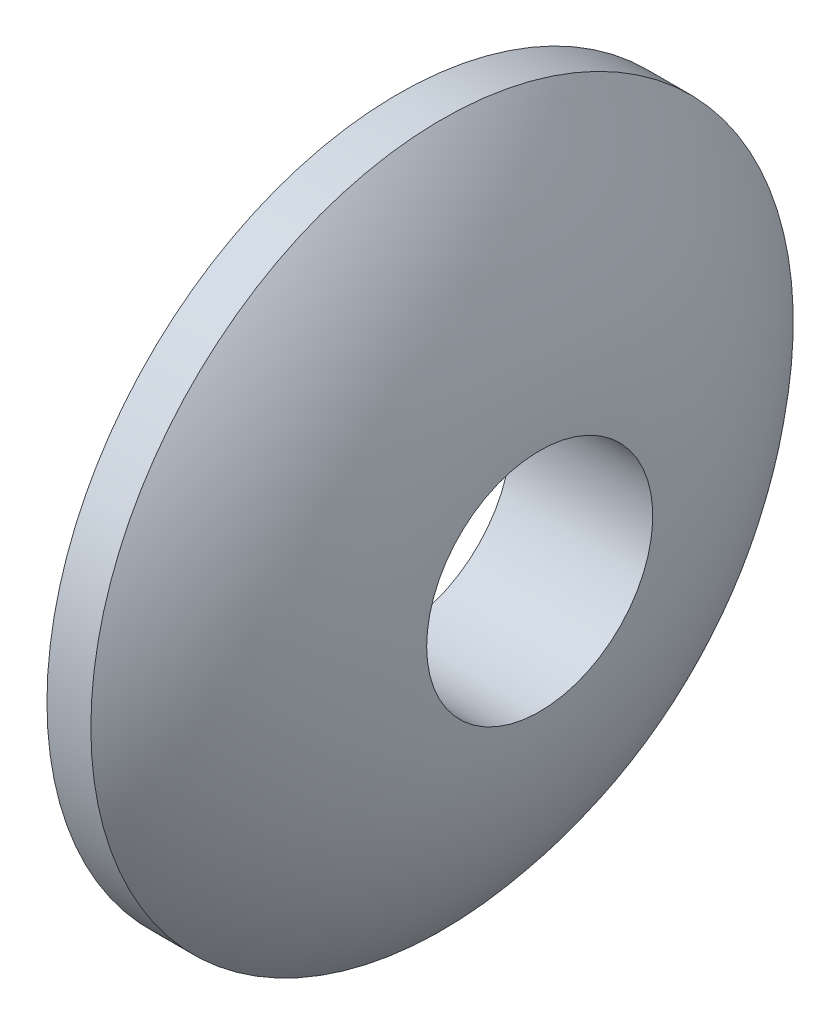
from build123d import *

# Parameters (mm, degrees)
SKETCH2_R          = 2.575
CUT_EXTRUDE1_DEPTH = 4.238860099


with BuildPart() as part:
    # Sketch1 → Revolve1 (revolve)
    with BuildSketch(Plane.XY):
        with BuildLine():
            Line((0, 0), (0, 8))
            Line((0, 8), (1, 8))
            ThreePointArc((1, 8), (2.9701425, 4.242535625), (3, 0))
            Line((3, 0), (0, 0))
        make_face()
    revolve(axis=Axis((-6.042194093, 0, 0), (1, 0, 0)))

    # Sketch2 → Cut-Extrude1 (cut, through all)
    with BuildSketch(Plane.ZY):
        Circle(SKETCH2_R)
    extrude(amount=-CUT_EXTRUDE1_DEPTH, mode=Mode.SUBTRACT)


solid = part.part
